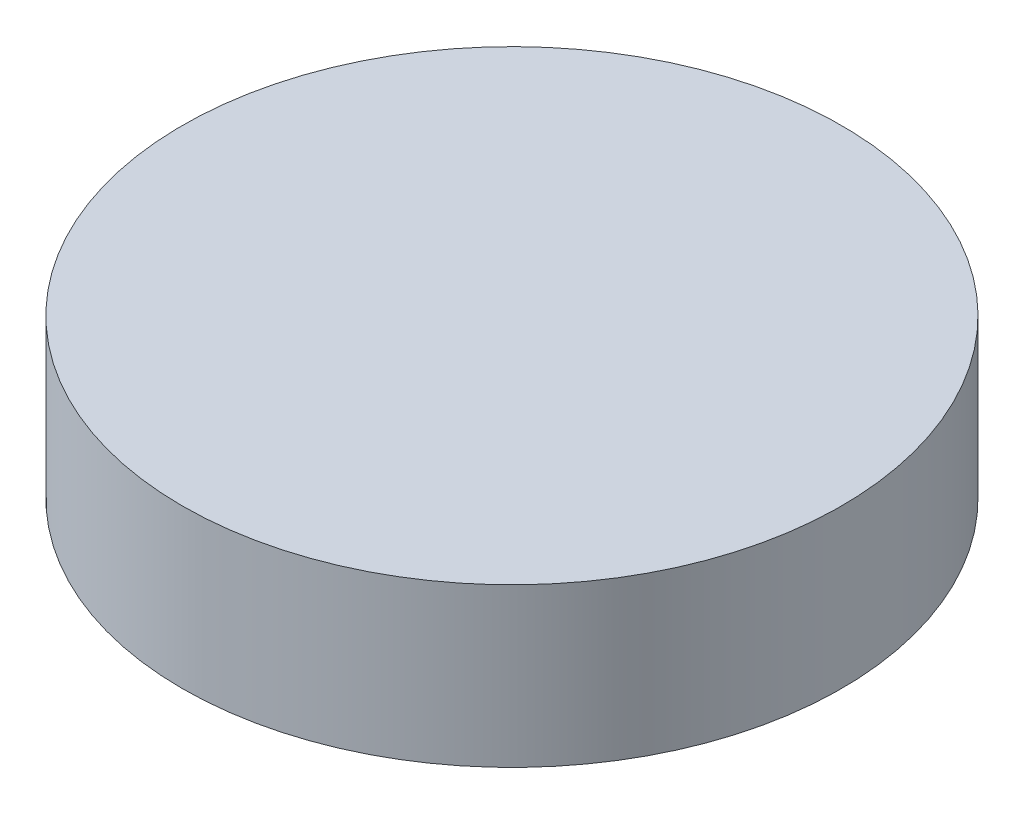
from build123d import *

# Parameters (mm, degrees)
SKETCH_1_R      = 6.25
EXTRUDE_1_DEPTH = 3


with BuildPart() as part:
    # 草图1 → 凸台-拉伸1 (new body)
    with BuildSketch(Plane(origin=(0, 0, 0), x_dir=(1, 0, 0), z_dir=(0, 1, 0))):
        with Locations(Location((0, 0, 0), (0, 0, 270))):  # turned: the seam where the file's is
            Circle(SKETCH_1_R)
    extrude(amount=EXTRUDE_1_DEPTH)


solid = part.part
